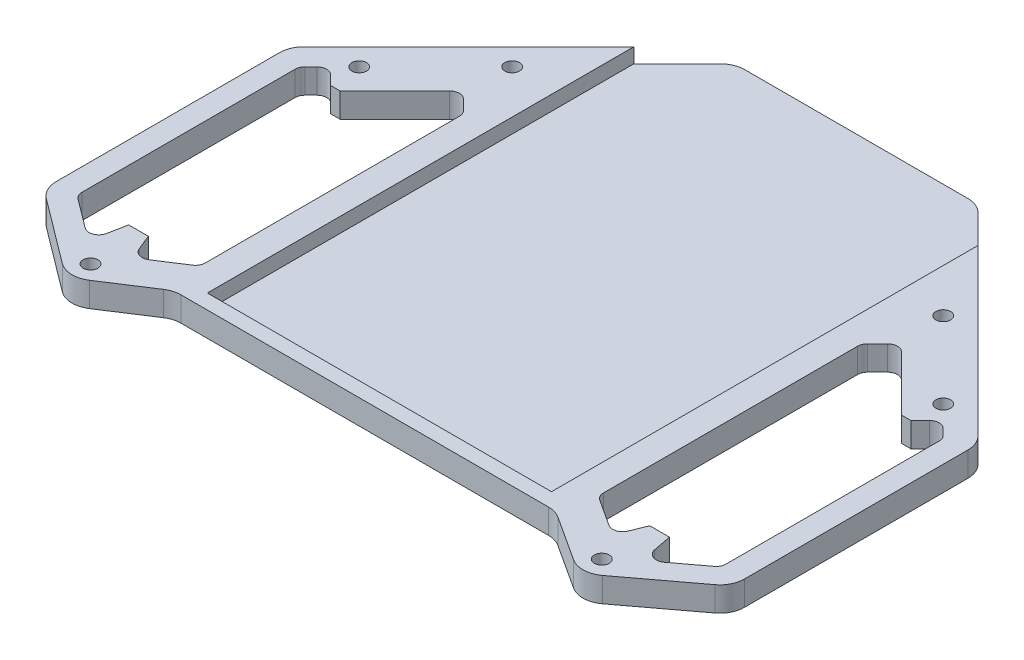
from build123d import *

# Parameters (mm, degrees)
SKETCH1_R            = 1.5
BOSS_EXTRUDE1_DEPTH  = 5
FILLET1_R            = 2
FILLET1_OF_MIRROR1_R = 2
SKETCH2_W            = 70
SKETCH2_H            = 97
CUT_EXTRUDE1_DEPTH   = 3
FILLET2_R            = 5


with BuildPart() as part:
    # Sketch1 → Boss-Extrude1 (new body)
    with BuildSketch(Plane(origin=(0, 0, 0), x_dir=(1, 0, 0), z_dir=(0, 1, 0))):
        Polygon((-52.164149312, -38.645247828), (-70, -25.247940817), (-70, 24.752308679), (-24.752308679, 70), (0, 70), (0, -30), (-38.851635079, -30), align=None)
        with Locations((-43.840620434, 43.840620434)):
            Circle(SKETCH1_R, mode=Mode.SUBTRACT)
        with Locations((-51.997575213, -33.767620171)):
            Circle(SKETCH1_R, mode=Mode.SUBTRACT)
        with Locations((-59.39696962, 28.284271247)):
            Circle(SKETCH1_R, mode=Mode.SUBTRACT)
        Polygon((-59.003765723, 22.1), (-57.095959493, 22.1), (-44.547727215, 34.648232278), (-40.5, 30.600505063), (-40.5, -23), (-48.796166422, -28.387593469), (-51, -23), (-55, -23), (-56.33662338, -29.883022962), (-65.5, -23), (-65.5, 22.181240867), (-62.292503295, 25.388737572), align=None, mode=Mode.SUBTRACT)
    boss_extrude1 = extrude(amount=BOSS_EXTRUDE1_DEPTH)

    # Fillet1
    fillet1_edges = [part.edges().sort_by_distance(p)[0] for p in [
        (-44.547727215, 2.5, -34.648232278),
        (-62.292503295, 2.5, -25.388737572),
        (-65.5, 2.5, -22.181240867),
        (-65.5, 2.5, 23),
        (-56.33662338, 2.5, 29.883022962),
        (-48.796166422, 2.5, 28.387593469),
        (-40.5, 2.5, 23),
        (-40.5, 2.5, -30.600505063),
    ]]
    fillet(fillet1_edges, radius=FILLET1_R)

    # Mirror1: Boss-Extrude1 across plane
    add(boss_extrude1.mirror(Plane(origin=(0, 5, 30), x_dir=(0, 0, 1), z_dir=(-1, 0, 0))))

    # Fillet1 of Mirror1
    fillet1_of_mirror1_edges = [part.edges().sort_by_distance(p)[0] for p in [
        (44.547727215, 2.5, -34.648232278),
        (62.292503295, 2.5, -25.388737572),
        (65.5, 2.5, -22.181240867),
        (65.5, 2.5, 23),
        (56.33662338, 2.5, 29.883022962),
        (48.796166422, 2.5, 28.387593469),
        (40.5, 2.5, 23),
        (40.5, 2.5, -30.600505063),
    ]]
    fillet(fillet1_of_mirror1_edges, radius=FILLET1_OF_MIRROR1_R)

    # Sketch2 → Cut-Extrude1 (cut)
    with BuildSketch(Plane(origin=(0, 5, 0), x_dir=(1, 0, 0), z_dir=(0, 1, 0))):
        with Locations((0, 21.5)):
            Rectangle(SKETCH2_W, SKETCH2_H)
    extrude(amount=-CUT_EXTRUDE1_DEPTH, mode=Mode.SUBTRACT)

    # Fillet2
    fillet2_edges = [part.edges().sort_by_distance(p)[0] for p in [
        (-70, 2.5, -24.752308679),
        (70, 2.5, 25.247940817),
        (70, 2.5, -24.752308679),
        (38.851635079, 2.5, 30),
        (-38.851635079, 2.5, 30),
        (52.164149312, 2.5, 38.645247828),
        (-52.164149312, 2.5, 38.645247828),
        (-70, 2.5, 25.247940817),
        (24.752308679, 1, -70),
        (-24.752308679, 1, -70),
    ]]
    fillet(fillet2_edges, radius=FILLET2_R)


solid = part.part
